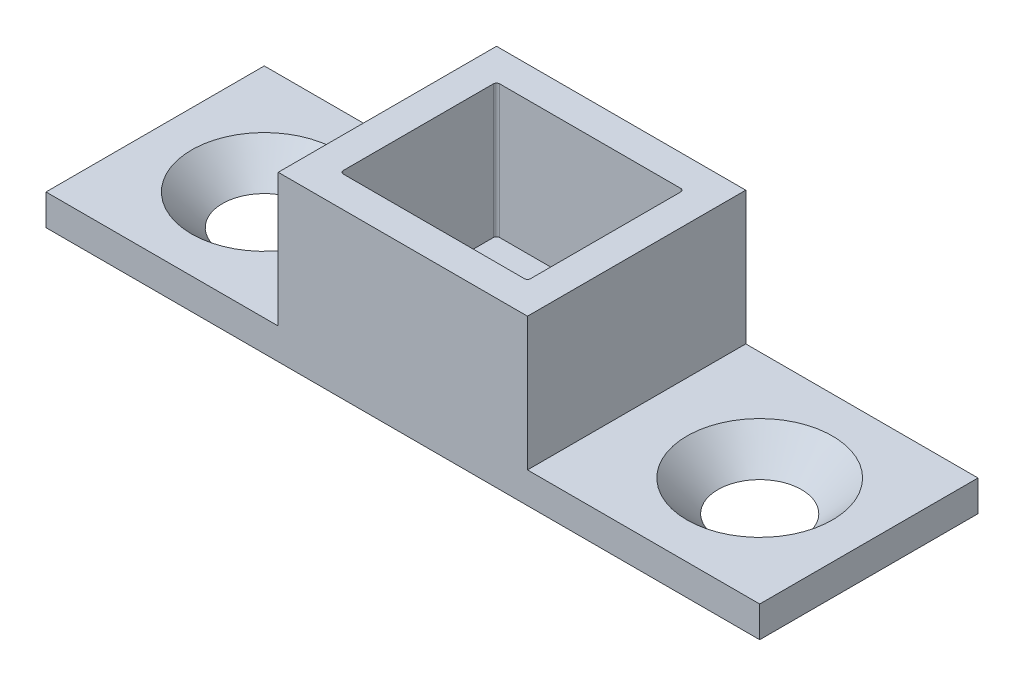
from build123d import *

# Parameters (mm, degrees)
SKETCH1_W                                            = 16.1
SKETCH1_H                                            = 14.1
BOSS_EXTRUDE1_DEPTH                                  = 10.6
SKETCH3_W                                            = 12.1
SKETCH3_H                                            = 10.1
CUT_EXTRUDE1_DEPTH                                   = 8.6
CSK_FOR_M1_6_COUNTERSUNK_FLAT_HEAD_SCREW_D           = 2
CSK_FOR_M1_6_COUNTERSUNK_FLAT_HEAD_SCREW_DEPTH       = 2
CSK_FOR_M1_6_COUNTERSUNK_FLAT_HEAD_SCREW_CSINK_D     = 4
CSK_FOR_M1_6_COUNTERSUNK_FLAT_HEAD_SCREW_CSINK_ANGLE = 90
SKETCH8_R                                            = 2.25
CUT_EXTRUDE2_DEPTH                                   = 3
FILLET2_R                                            = 0.2
SKETCH9_W                                            = 15
SKETCH9_H                                            = 14.1
BOSS_EXTRUDE2_DEPTH                                  = 2


with BuildPart() as part:
    # Sketch1 → Boss-Extrude1 (new body)
    with BuildSketch(Plane(origin=(0, 0, 0), x_dir=(1, 0, 0), z_dir=(0, 1, 0))):
        Rectangle(SKETCH1_W, SKETCH1_H)
    extrude(amount=BOSS_EXTRUDE1_DEPTH)

    # Sketch3 → Cut-Extrude1 (cut)
    with BuildSketch(Plane(origin=(0, 10.6, 0), x_dir=(1, 0, 0), z_dir=(0, 1, 0))):
        Rectangle(SKETCH3_W, SKETCH3_H)
    extrude(amount=-CUT_EXTRUDE1_DEPTH, mode=Mode.SUBTRACT)

    # CSK for M1.6 Countersunk Flat Head Screw1
    with Locations(Plane(origin=(0, 0, 0), x_dir=(-1, 0, 0), z_dir=(0, -1, 0))):
        with Locations((4.5, 0), (-4.5, 0)):
            CounterSinkHole(CSK_FOR_M1_6_COUNTERSUNK_FLAT_HEAD_SCREW_D / 2, CSK_FOR_M1_6_COUNTERSUNK_FLAT_HEAD_SCREW_CSINK_D / 2, depth=CSK_FOR_M1_6_COUNTERSUNK_FLAT_HEAD_SCREW_DEPTH, counter_sink_angle=CSK_FOR_M1_6_COUNTERSUNK_FLAT_HEAD_SCREW_CSINK_ANGLE)

    # Sketch8 → Cut-Extrude2 (cut, through all)
    with BuildSketch(Plane(origin=(0, 2, 0), x_dir=(1, 0, 0), z_dir=(0, 1, 0))):
        Circle(SKETCH8_R)
    extrude(amount=-CUT_EXTRUDE2_DEPTH, mode=Mode.SUBTRACT)

    # Fillet2
    fillet2_edges = [part.edges().sort_by_distance(p)[0] for p in [
        (-6.05, 6.3, 5.05),
        (-6.05, 6.3, -5.05),
        (6.05, 6.3, -5.05),
        (6.05, 6.3, 5.05),
    ]]
    fillet(fillet2_edges, radius=FILLET2_R)

    # Sketch9 → Boss-Extrude2 (add)
    with BuildSketch(Plane(origin=(0, 0, 0), x_dir=(1, 0, 0), z_dir=(0, 1, 0))):
        with Locations((-15.55, 0)):
            Rectangle(SKETCH9_W, SKETCH9_H)
    boss_extrude2 = extrude(amount=BOSS_EXTRUDE2_DEPTH)

    # Sketch11 → CSK for M4 Countersunk Flat Head Screw1 (revolve, cut)
    with BuildSketch(Plane(origin=(-16, 2, 0), x_dir=(0, 0, 1), z_dir=(1, 0, 0))):
        Polygon((0, 0), (0, 2.001), (2.4, 2.001), (2.4, 2.3), (4.7, 0), align=None)
    csk_for_m4_countersunk_flat_head_screw1 = revolve(axis=Axis((-16, 8.35, 0), (0, -1, 0)), mode=Mode.SUBTRACT)

    # Mirror1: Boss-Extrude2, CSK for M4 Countersunk Flat Head Screw1 across plane
    add(boss_extrude2.mirror(Plane(origin=(0, 0, 0), x_dir=(0, 0, 1), z_dir=(1, 0, 0))))
    add(csk_for_m4_countersunk_flat_head_screw1.mirror(Plane(origin=(0, 0, 0), x_dir=(0, 0, 1), z_dir=(1, 0, 0))), mode=Mode.SUBTRACT)


solid = part.part
